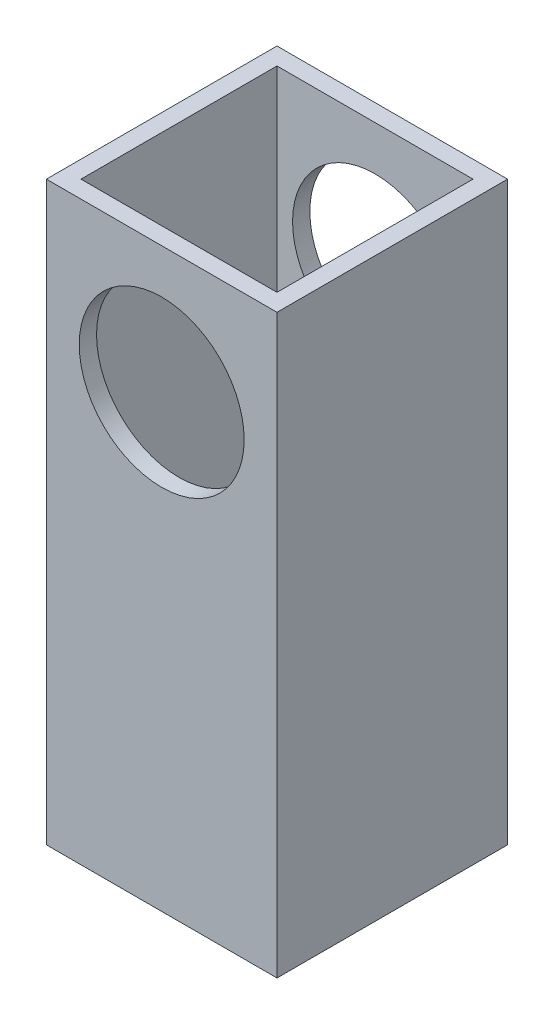
from build123d import *

# Parameters (mm, degrees)
SKETCH1_W           = 40
SKETCH1_H           = 100
BOSS_EXTRUDE2_DEPTH = 40
SKETCH2_R           = 14.3
CUT_EXTRUDE1_DEPTH  = 41
SKETCH3_W           = 34
SKETCH3_H           = 34
CUT_EXTRUDE2_DEPTH  = 101


with BuildPart() as part:
    # Sketch1 → Boss-Extrude2 (new body)
    with BuildSketch(Plane.XY):
        Rectangle(SKETCH1_W, SKETCH1_H)
    extrude(amount=BOSS_EXTRUDE2_DEPTH)

    # Sketch2 → Cut-Extrude1 (cut, through all)
    with BuildSketch(Plane.XY.offset(40)):
        with Locations((0, 28)):
            Circle(SKETCH2_R)
    extrude(amount=-CUT_EXTRUDE1_DEPTH, mode=Mode.SUBTRACT)

    # Sketch3 → Cut-Extrude2 (cut, through all)
    with BuildSketch(Plane(origin=(0, 50, 0), x_dir=(1, 0, 0), z_dir=(0, 1, 0))):
        with Locations((0, -20)):
            Rectangle(SKETCH3_W, SKETCH3_H)
    extrude(amount=-CUT_EXTRUDE2_DEPTH, mode=Mode.SUBTRACT)


solid = part.part
